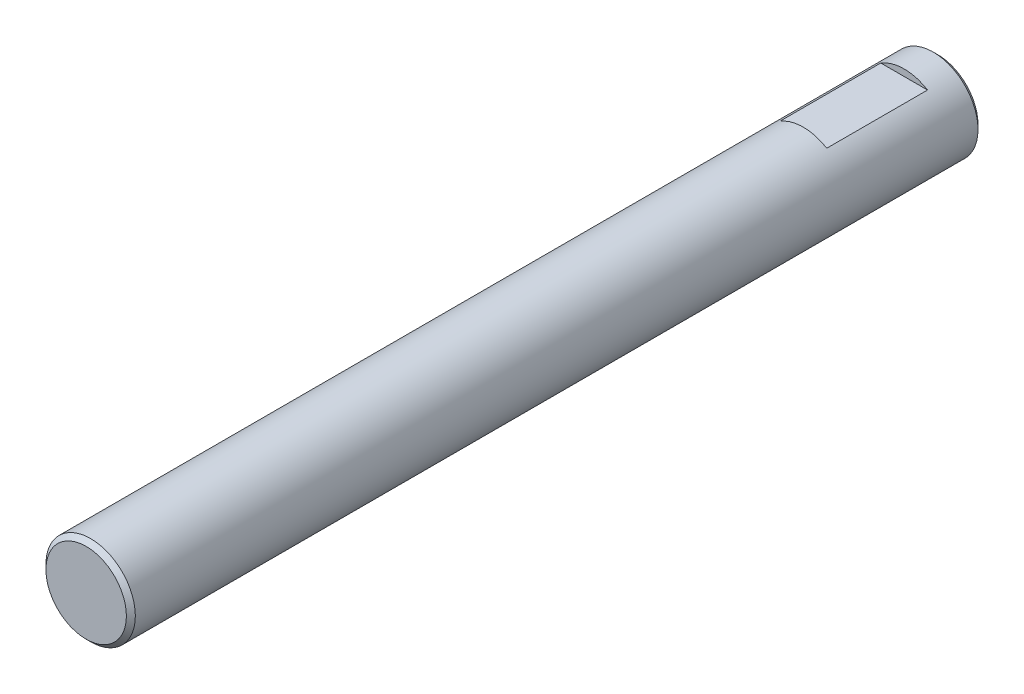
from build123d import *

# Parameters (mm, degrees)
SKETCH1_R               = 1.995
BOSS_EXTRUDE1_DEPTH     = 38
SKETCH2_W               = 4.5
SKETCH2_H               = 0.920377874
CUT_EXTRUDE1_DEPTH      = 2.995
CUT_EXTRUDE1_DEPTH_BACK = 2.995
CHAMFER1_SIZE           = 0.2


with BuildPart() as part:
    # Sketch1 → Boss-Extrude1 (new body)
    with BuildSketch(Plane.XY):
        Circle(SKETCH1_R)
    extrude(amount=BOSS_EXTRUDE1_DEPTH)

    # Sketch2 → Cut-Extrude1 (cut, two sides)
    with BuildSketch(Plane(origin=(0, 0, 0), x_dir=(0, 0, -1), z_dir=(1, 0, 0))) as cut_extrude1_sk:
        with Locations((-3.75, 2.160188937)):
            Rectangle(SKETCH2_W, SKETCH2_H)
        with Locations((-3.75, -2.160188937)):
            Rectangle(SKETCH2_W, SKETCH2_H)
    extrude(amount=CUT_EXTRUDE1_DEPTH, mode=Mode.SUBTRACT)
    extrude(cut_extrude1_sk.sketch, amount=-CUT_EXTRUDE1_DEPTH_BACK, mode=Mode.SUBTRACT)

    # Chamfer1
    chamfer1_edges = [part.edges().sort_by_distance(p)[0] for p in [
        (-1.995, 0, 0),
        (-1.995, 0, 38),
    ]]
    chamfer(chamfer1_edges, length=CHAMFER1_SIZE)


solid = part.part
